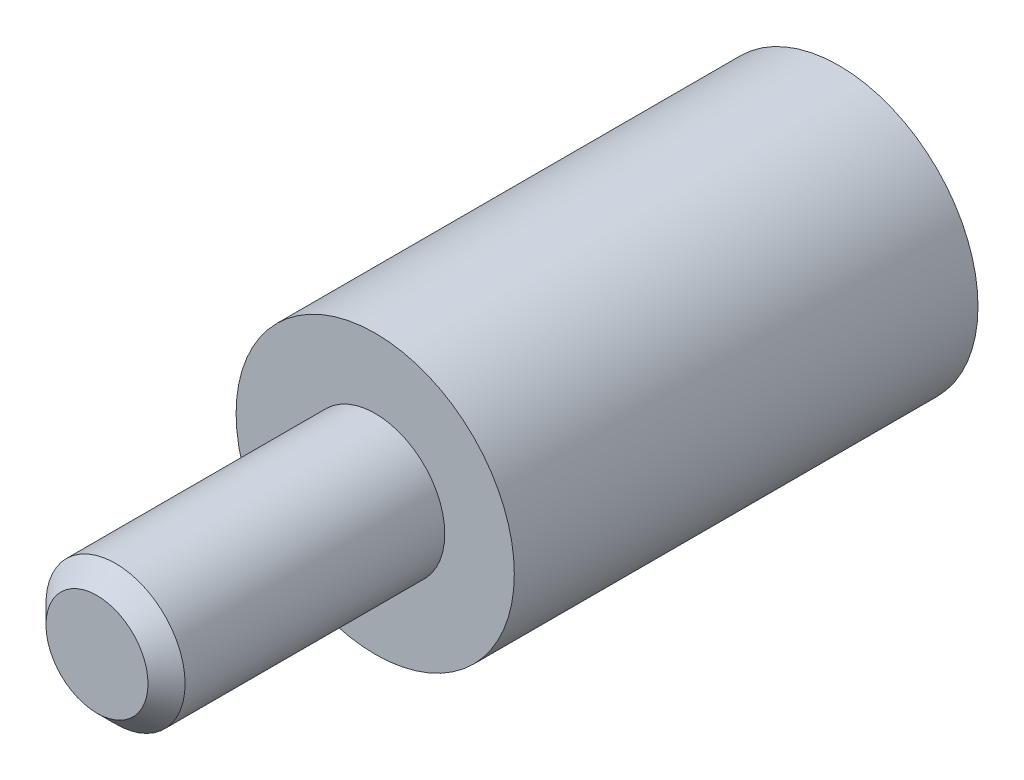
from build123d import *

# Parameters (mm, degrees)
SKETCH_1_R      = 3
EXTRUDE_1_DEPTH = 10
SKETCH_2_R      = 1.5
EXTRUDE_2_DEPTH = 6
M3X0_5_1_D      = 2.5
M3X0_5_1_DEPTH  = 8.5
M3X0_5_1_TIP    = 0.751075774
CHAMFER_1_SIZE  = 0.4


with BuildPart() as part:
    # ｽｹｯﾁ1 → ﾎﾞｽ - 押し出し1 (new body)
    with BuildSketch(Plane(origin=(0, 0, 0), x_dir=(0, 1, 0), z_dir=(0, 0, 1))):
        Circle(SKETCH_1_R)
    extrude(amount=EXTRUDE_1_DEPTH)

    # ｽｹｯﾁ2 → ﾎﾞｽ - 押し出し2 (add)
    with BuildSketch(Plane.XY.offset(10)):
        Circle(SKETCH_2_R)
    extrude(amount=EXTRUDE_2_DEPTH)

    # M3x0.5 ねじ穴1
    with Locations(Plane(origin=(0, 0, 0), x_dir=(1, 0, 0), z_dir=(0, 0, -1))):
        with Locations((0, 0)):
            Hole(M3X0_5_1_D / 2, depth=M3X0_5_1_DEPTH)
            with Locations((0, 0, -(M3X0_5_1_DEPTH + M3X0_5_1_TIP / 2))):  # 118° drill point
                Cone(0, M3X0_5_1_D / 2, M3X0_5_1_TIP, mode=Mode.SUBTRACT)

    # 面取り1
    chamfer_1_edges = [part.edges().sort_by_distance(p)[0] for p in [
        (1.25, 0, 0),
        (-1.5, 0, 16),
    ]]
    chamfer(chamfer_1_edges, length=CHAMFER_1_SIZE)


solid = part.part
